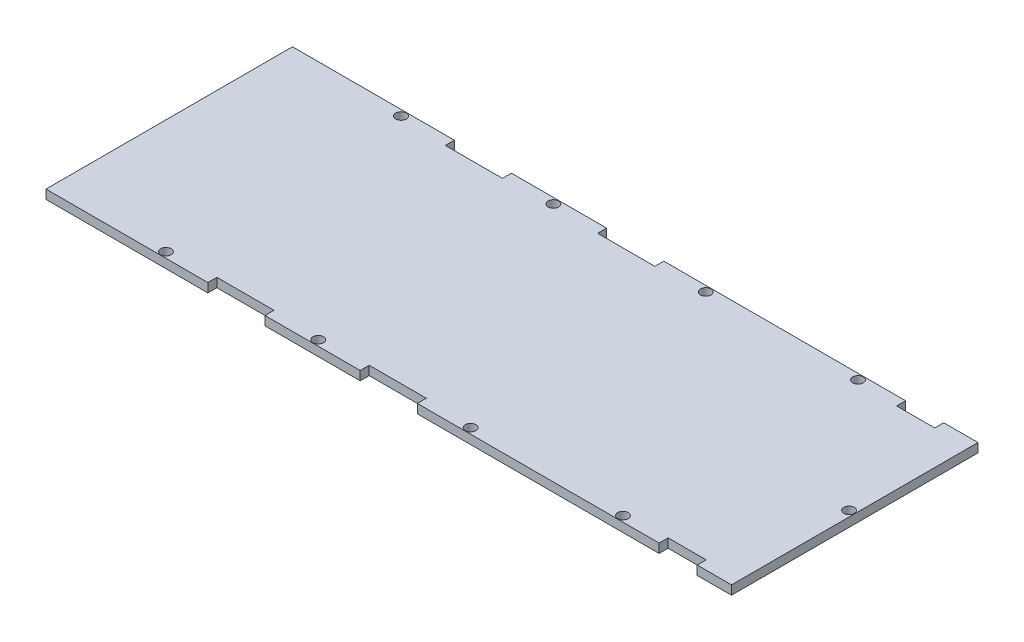
from build123d import *

# Parameters (mm, degrees)
SKETCH1_R           = 1.7526
BOSS_EXTRUDE1_DEPTH = 3


with BuildPart() as part:
    # Sketch1 → Boss-Extrude1 (new body)
    with BuildSketch(Plane(origin=(0, 0, 0), x_dir=(1, 0, 0), z_dir=(0, 1, 0))):
        Polygon((114.3, -0.83215209), (114.3, -41.1), (102.87, -41.1), (102.87, -38.1), (90.17, -38.1), (90.17, -41.1), (89.493211941, -41.1), (77.528882775, -41.1), (74.871117225, -41.1), (26.728882775, -41.1), (24.071117225, -41.1), (9.525, -41.1), (9.525, -38.1), (-9.525, -38.1), (-9.525, -41.1), (-24.071117225, -41.1), (-26.728882775, -41.1), (-41.275, -41.1), (-41.275, -38.1), (-60.325, -38.1), (-60.325, -41.1), (-74.871117225, -41.1), (-77.528882775, -41.1), (-114.3, -41.1), (-114.3, 41.1), (-77.528882775, 41.1), (-74.871117225, 41.1), (-60.325, 41.1), (-60.325, 38.1), (-41.275, 38.1), (-41.275, 41.1), (-26.728882775, 41.1), (-24.071117225, 41.1), (-9.525, 41.1), (-9.525, 38.1), (9.525, 38.1), (9.525, 41.1), (24.071117225, 41.1), (26.728882775, 41.1), (74.871117225, 41.1), (77.528882775, 41.1), (89.493211941, 41.1), (90.17, 41.1), (90.17, 38.1), (102.87, 38.1), (102.87, 41.1), (114.3, 41.1), (114.3, 1.18215209), align=None)
        with Locations((-25.4, -39.195)):
            Circle(SKETCH1_R, mode=Mode.SUBTRACT)
        with Locations((112.395, 0)):
            Circle(SKETCH1_R, mode=Mode.SUBTRACT)
        with Locations((25.4, -39.195)):
            Circle(SKETCH1_R, mode=Mode.SUBTRACT)
        with Locations((76.2, -39.195)):
            Circle(SKETCH1_R, mode=Mode.SUBTRACT)
        with Locations((76.2, 39.195)):
            Circle(SKETCH1_R, mode=Mode.SUBTRACT)
        with Locations((25.4, 39.195)):
            Circle(SKETCH1_R, mode=Mode.SUBTRACT)
        with Locations((-25.4, 39.195)):
            Circle(SKETCH1_R, mode=Mode.SUBTRACT)
        with Locations((-76.2, 39.195)):
            Circle(SKETCH1_R, mode=Mode.SUBTRACT)
        with Locations((-76.2, -39.195)):
            Circle(SKETCH1_R, mode=Mode.SUBTRACT)
    extrude(amount=BOSS_EXTRUDE1_DEPTH)


solid = part.part
